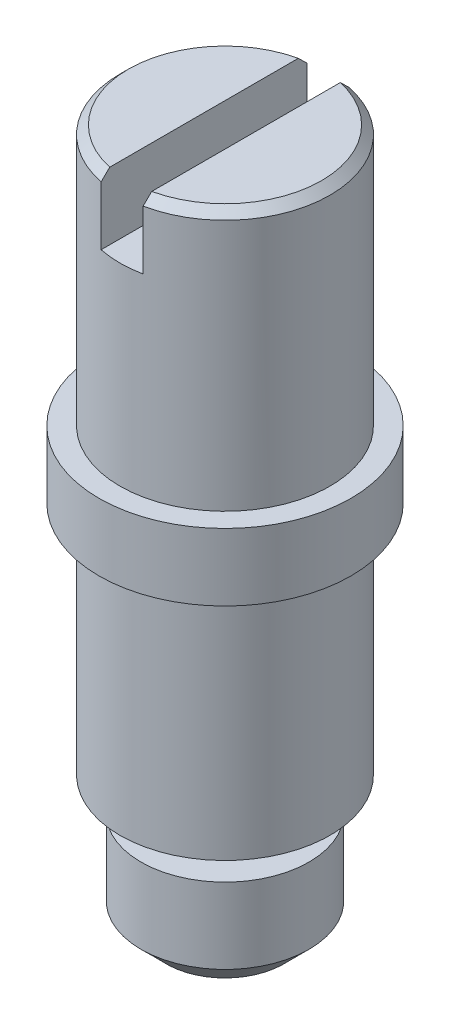
from build123d import *

# Parameters (mm, degrees)
SKETCH1_R               = 0.75
BOSS_EXTRUDE1_DEPTH     = 0.4
SKETCH2_R               = 0.625
BOSS_EXTRUDE2_DEPTH     = 1.55
SKETCH3_R               = 0.625
BOSS_EXTRUDE3_DEPTH     = 1.4
SKETCH4_R               = 0.3
BOSS_EXTRUDE4_DEPTH     = 0.2
SKETCH5_R               = 0.5
BOSS_EXTRUDE5_DEPTH     = 0.6
CHAMFER1_SIZE           = 0.05
CHAMFER2_SIZE           = 0.15
CUT_EXTRUDE1_DEPTH      = 1.75
CUT_EXTRUDE1_DEPTH_BACK = 1.75


with BuildPart() as part:
    # Sketch1 → Boss-Extrude1 (new body)
    with BuildSketch(Plane(origin=(0, 0, 0), x_dir=(1, 0, 0), z_dir=(0, 1, 0))):
        Circle(SKETCH1_R)
    extrude(amount=BOSS_EXTRUDE1_DEPTH)

    # Sketch2 → Boss-Extrude2 (add)
    with BuildSketch(Plane(origin=(0, 0.4, 0), x_dir=(1, 0, 0), z_dir=(0, 1, 0))):
        Circle(SKETCH2_R)
    extrude(amount=BOSS_EXTRUDE2_DEPTH)

    # Sketch3 → Boss-Extrude3 (add)
    with BuildSketch(Plane(origin=(0, 0, 0), x_dir=(1, 0, 0), z_dir=(0, 1, 0))):
        Circle(SKETCH3_R)
    extrude(amount=-BOSS_EXTRUDE3_DEPTH)

    # Sketch4 → Boss-Extrude4 (add)
    with BuildSketch(Plane.XZ.offset(1.4)):
        Circle(SKETCH4_R)
    extrude(amount=BOSS_EXTRUDE4_DEPTH)

    # Sketch5 → Boss-Extrude5 (add)
    with BuildSketch(Plane.XZ.offset(1.6)):
        Circle(SKETCH5_R)
    extrude(amount=BOSS_EXTRUDE5_DEPTH)

    # Chamfer1
    chamfer1_edges = [part.edges().sort_by_distance(p)[0] for p in [
        (-0.625, 1.95, 0),
    ]]
    chamfer(chamfer1_edges, length=CHAMFER1_SIZE)

    # Chamfer2
    chamfer2_edges = [part.edges().sort_by_distance(p)[0] for p in [
        (-0.5, -2.2, 0),
    ]]
    chamfer(chamfer2_edges, length=CHAMFER2_SIZE)

    # Sketch6 → Cut-Extrude1 (cut, two sides)
    with BuildSketch(Plane.XY) as cut_extrude1_sk:
        Polygon((0.125, 2.131643459), (-0.125, 2.131643459), (-0.125, 1.55), (0, 1.55), (0.125, 1.55), align=None)
    extrude(amount=CUT_EXTRUDE1_DEPTH, mode=Mode.SUBTRACT)
    extrude(cut_extrude1_sk.sketch, amount=-CUT_EXTRUDE1_DEPTH_BACK, mode=Mode.SUBTRACT)


solid = part.part
